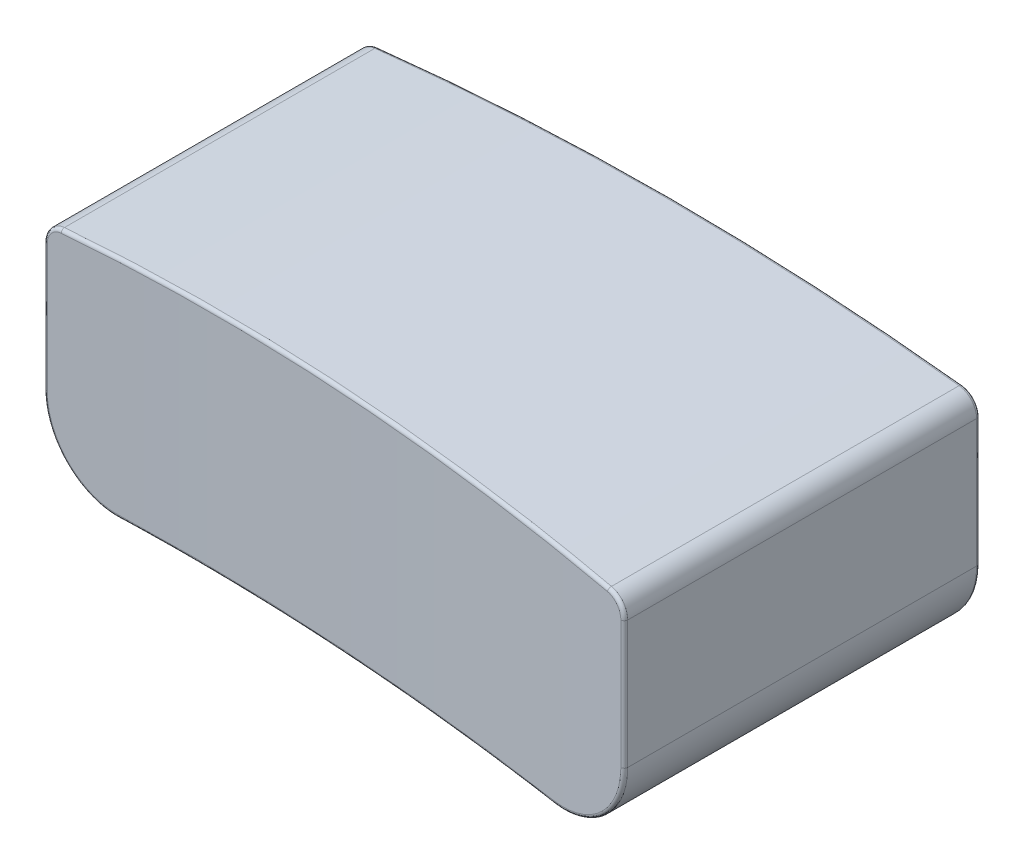
from build123d import *

# Parameters (mm, degrees)
SKETCH1_W               = 9.4
SKETCH1_H               = 3.7
BOSS_EXTRUDE1_DEPTH     = 2.7
CUT_EXTRUDE1_DEPTH      = 7.6
FILLET1_R               = 1.1
FILLET2_R               = 0.3
CUT_EXTRUDE2_START      = -1
SKETCH3_R               = 0.5
CUT_EXTRUDE2_DEPTH      = 13
FILLET4_R               = 0.02
CUT_EXTRUDE3_DEPTH      = 5
FILLET5_R               = 0.05
CUT_EXTRUDE4_REACH      = 18.72
CUT_EXTRUDE4_END_RADIUS = 50.4
CUT_EXTRUDE4_START      = -11
SKETCH5_R               = 0.4
FILLET6_R               = 0.05


with BuildPart() as part:
    # Sketch1 → Boss-Extrude1 (new, symmetric)
    with BuildSketch(Plane.XY):
        Rectangle(SKETCH1_W, SKETCH1_H)
    extrude(amount=BOSS_EXTRUDE1_DEPTH, both=True)

    # Sketch2 → Cut-Extrude1 (cut, symmetric)
    with BuildSketch(Plane.XY.offset(2.7)):
        with BuildLine():
            Line((-4.7, 1.55), (-7.120690005, 4.011417256))
            Line((-7.120690005, 4.011417256), (5.535860742, 3.886722174))
            Line((5.535860742, 3.886722174), (4.7, 1.55))
            ThreePointArc((4.7, 1.55), (0, 1.827084699), (-4.7, 1.55))
        make_face()
        with BuildLine():
            Line((4.7, -1.85), (0.350623614, -3.782025322))
            Line((0.350623614, -3.782025322), (-4.7, -1.85))
            ThreePointArc((-4.7, -1.85), (0, -1.628609864), (4.7, -1.85))
        make_face()
    extrude(amount=CUT_EXTRUDE1_DEPTH, both=True, mode=Mode.SUBTRACT)

    # Fillet1
    fillet1_edges = [part.edges().sort_by_distance(p)[0] for p in [
        (4.7, -1.85, 0),
        (-4.7, -1.85, 0),
    ]]
    fillet(fillet1_edges, radius=FILLET1_R)

    # Fillet2
    fillet2_edges = [part.edges().sort_by_distance(p)[0] for p in [
        (4.7, 1.55, 0),
        (-4.7, 1.55, 0),
    ]]
    fillet(fillet2_edges, radius=FILLET2_R)

    # Sketch3 → Cut-Extrude2 (cut)
    with BuildSketch(Plane.XY.offset(2.7).offset(CUT_EXTRUDE2_START)):
        with Locations((3.7, -0.6)):
            Circle(SKETCH3_R)
        with Locations((-3.7, -0.6)):
            Circle(SKETCH3_R)
    extrude(amount=-CUT_EXTRUDE2_DEPTH, mode=Mode.SUBTRACT)

    # Fillet4
    fillet4_edges = [part.edges().sort_by_distance(p)[0] for p in [
        (3.2, -0.6, -2.7),
        (-4.2, -0.6, -2.7),
    ]]
    fillet(fillet4_edges, radius=FILLET4_R)

    # Sketch4 → Cut-Extrude3 (cut, symmetric)
    with BuildSketch(Plane(origin=(0, 0, 0), x_dir=(1, 0, 0), z_dir=(0, 1, 0))):
        with BuildLine():
            Line((-4.7, -2.1), (-6.612719149, -3.713907535))
            Line((-6.612719149, -3.713907535), (6.420677859, -4.574089961))
            Line((6.420677859, -4.574089961), (4.7, -2.7))
            ThreePointArc((4.7, -2.7), (0.004710726, -2.326198627), (-4.7, -2.1))
        make_face()
    extrude(amount=CUT_EXTRUDE3_DEPTH, both=True, mode=Mode.SUBTRACT)

    # Fillet5
    fillet5_edges = [part.edges().sort_by_distance(p)[0] for p in [
        (4.7, 0.3134624, -2.7),
        (4.7, 0.3134624, 2.7),
        (0, -1.628609864, -2.7),
        (-4.349918456, -1.460327621, -2.7),
        (4.349918456, -1.460327621, -2.7),
        (0, 1.827084699, -2.7),
        (-4.7, 0.3134624, -2.7),
        (-4.623578634, 1.482534062, -2.7),
        (4.623578634, 1.482534062, -2.7),
        (3.2, -0.6, 1.7),
        (-4.623553452, 1.482562201, 2.102492735),
        (4.349071617, -1.461115931, 2.666925629),
        (-4.349757648, -1.460477444, 2.11174073),
        (4.623384051, 1.482751335, 2.692708088),
        (0.002641899, -1.628609931, 2.326066603),
        (-4.7, 0.3134624, 2.1),
        (0.004177998, 1.827084481, 2.326164624),
    ]]
    fillet(fillet5_edges, radius=FILLET5_R)

    # Cut-Extrude4: up to this cylinder (the profile starts inside it)
    cut_extrude4_end = Plane(origin=(0, -51.628609864, -1.2), z_dir=(0, 0, 1)) * Cylinder(CUT_EXTRUDE4_END_RADIUS, 139.24, mode=Mode.PRIVATE)
    # Sketch5 → Cut-Extrude4 (cut, up to the surface)
    with BuildSketch(Plane(origin=(0, 0, 0), x_dir=(1, 0, 0), z_dir=(0, 1, 0)).offset(CUT_EXTRUDE4_START), mode=Mode.PRIVATE) as cut_extrude4_sk1:
        with Locations(Location((-0.7, 1.2, 0), (0, 0, 90))):
            Circle(SKETCH5_R)
    cut_extrude4_tool1 = extrude(cut_extrude4_sk1.sketch, amount=CUT_EXTRUDE4_REACH, mode=Mode.PRIVATE) & cut_extrude4_end
    add(cut_extrude4_tool1.solids().sort_by_distance((-0.7, -11, -1.2))[0], mode=Mode.SUBTRACT)

    # Fillet6
    fillet6_edges = [part.edges().sort_by_distance(p)[0] for p in [
        (-0.700029875, -1.633510522, -0.800000001),
    ]]
    fillet(fillet6_edges, radius=FILLET6_R)


solid = part.part
